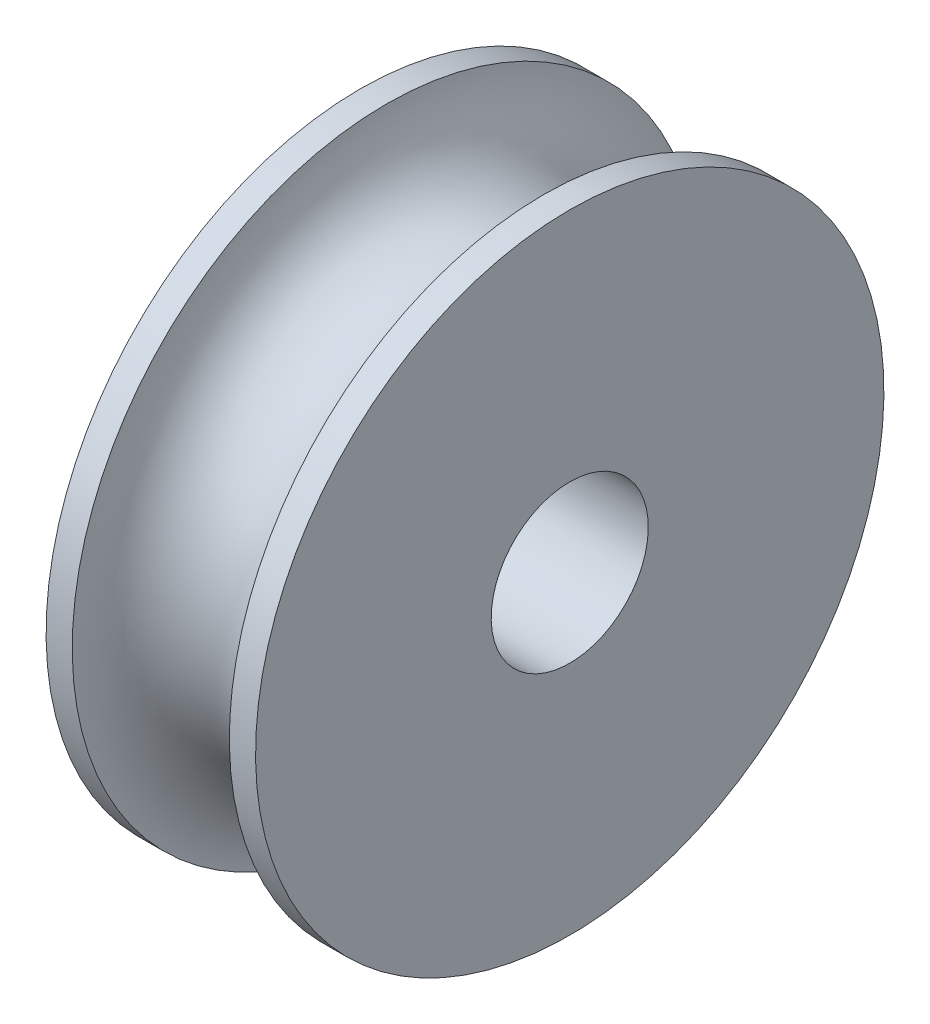
from build123d import *

# Parameters (mm, degrees)
SKIZZE2_R                       = 1.5
SCHNITT_LINEAR_AUSTRAGEN1_DEPTH = 10


with BuildPart() as part:
    # Skizze1 → Rotation1 (revolve)
    with BuildSketch(Plane.XY):
        with BuildLine():
            Line((0, 0), (-4, 0))
            Line((-4, 0), (-4, 6))
            Line((-4, 6), (-3.5, 6))
            ThreePointArc((-3.5, 6), (-2, 4.5), (-0.5, 6))
            Line((-0.5, 6), (0, 6))
            Line((0, 6), (0, 0))
        make_face()
    revolve(axis=Axis((0, 0, 0), (-1, 0, 0)))

    # Skizze2 → Schnitt-Linear austragen1 (cut)
    with BuildSketch(Plane(origin=(0, 0, 0), x_dir=(0, 0, -1), z_dir=(1, 0, 0))):
        Circle(SKIZZE2_R)
    extrude(amount=-SCHNITT_LINEAR_AUSTRAGEN1_DEPTH, mode=Mode.SUBTRACT)


solid = part.part
